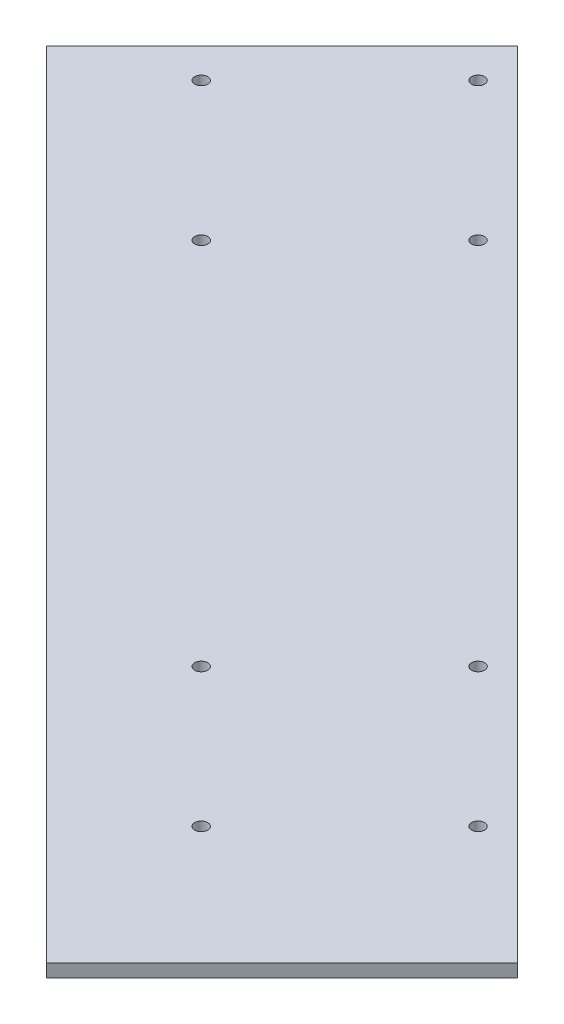
from build123d import *

# Parameters (mm, degrees)
CROQUIS2_W              = 1300
CROQUIS2_H              = 1000
SALIENTE_EXTRUIR1_DEPTH = 10
CROQUIS3_R              = 5
CORTAR_EXTRUIR1_DEPTH   = 11
CORTAR_EXTRUIR2_DEPTH   = 10
CORTAR_EXTRUIR3_DEPTH   = 10
CUT_EXTRUDE1_DEPTH      = 11


with BuildPart() as part:
    # Croquis2 → Saliente-Extruir1 (new body)
    with BuildSketch(Plane(origin=(0, 0, 0), x_dir=(1, 0, 0), z_dir=(0, 1, 0))):
        Rectangle(CROQUIS2_W, CROQUIS2_H)
    extrude(amount=SALIENTE_EXTRUIR1_DEPTH)

    # Croquis3 → Cortar-Extruir1 (cut, through all)
    with BuildSketch(Plane(origin=(0, 10, 0), x_dir=(1, 0, 0), z_dir=(0, 1, 0))):
        with Locations((-72.831998462, -137.867965644)):
            Circle(CROQUIS3_R)
        with Locations((33.234018716, -243.933982822)):
            Circle(CROQUIS3_R)
        with Locations((-72.831998462, -350)):
            Circle(CROQUIS3_R)
        with Locations((-178.89801564, -243.933982822)):
            Circle(CROQUIS3_R)
        with Locations((-461.740728115, 251.040764009)):
            Circle(CROQUIS3_R)
        with Locations((-355.674710937, 144.974746831)):
            Circle(CROQUIS3_R)
        with Locations((-461.740728115, 38.908729653)):
            Circle(CROQUIS3_R)
        with Locations((-567.806745293, 144.974746831)):
            Circle(CROQUIS3_R)
    extrude(amount=-CORTAR_EXTRUIR1_DEPTH, mode=Mode.SUBTRACT)

    # Croquis5 → Cortar-Extruir2 (cut)
    with BuildSketch(Plane(origin=(0, 0, 0), x_dir=(1, 0, 0), z_dir=(0, 1, 0))):
        Polygon((0, 0), (-500, 500), (650, 500), (650, -500), (500, -500), align=None)
        Polygon((-41.541714007, -500), (-650, 108.458285993), (-650, -500), align=None)
    extrude(amount=CORTAR_EXTRUIR2_DEPTH, mode=Mode.SUBTRACT)

    # Croquis6 → Cortar-Extruir3 (cut)
    with BuildSketch(Plane(origin=(0, 0, 0), x_dir=(1, 0, 0), z_dir=(0, 1, 0))):
        Polygon((-650, 108.458285993), (-379.229142997, 379.229142997), (-500, 500), (-650, 500), align=None)
        Polygon((-41.541714007, -500), (229.229142997, -229.229142997), (500, -500), align=None)
    extrude(amount=CORTAR_EXTRUIR3_DEPTH, mode=Mode.SUBTRACT)

    # Sketch1 → Cut-Extrude1 (cut, through all)
    with BuildSketch(Plane(origin=(0, 10, 0), x_dir=(1, 0, 0), z_dir=(0, 1, 0))):
        Polygon((-379.229142997, 379.229142997), (-469.383041958, 289.075244036), (139.075244036, -319.383041958), (229.229142997, -229.229142997), align=None)
    extrude(amount=-CUT_EXTRUDE1_DEPTH, mode=Mode.SUBTRACT)


solid = part.part
